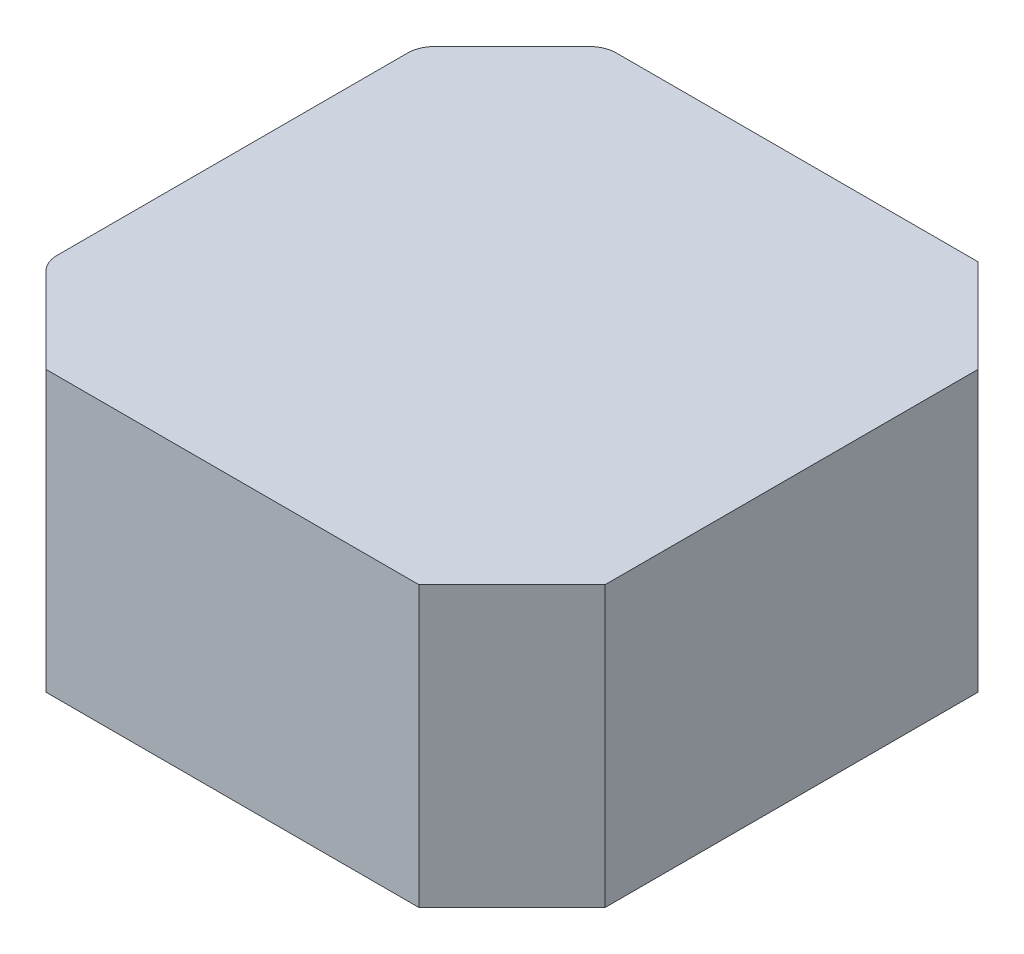
from build123d import *

# Parameters (mm, degrees)
SKETCH1_W           = 42
SKETCH1_H           = 42
BOSS_EXTRUDE1_DEPTH = 21
CHAMFER1_SIZE       = 7
FILLET1_R           = 2


with BuildPart() as part:
    # Sketch1 → Boss-Extrude1 (new body)
    with BuildSketch(Plane(origin=(0, 0, 0), x_dir=(1, 0, 0), z_dir=(0, 1, 0))):
        Rectangle(SKETCH1_W, SKETCH1_H)
    extrude(amount=BOSS_EXTRUDE1_DEPTH)

    # Chamfer1
    chamfer1_edges = [part.edges().sort_by_distance(p)[0] for p in [
        (-21, 10.5, -21),
        (21, 10.5, -21),
        (21, 10.5, 21),
        (-21, 10.5, 21),
    ]]
    chamfer(chamfer1_edges, length=CHAMFER1_SIZE)

    # Fillet1
    fillet1_edges = [part.edges().sort_by_distance(p)[0] for p in [
        (-21, 10.5, 14),
        (-21, 10.5, -14),
        (-14, 10.5, -21),
    ]]
    fillet(fillet1_edges, radius=FILLET1_R)


solid = part.part
